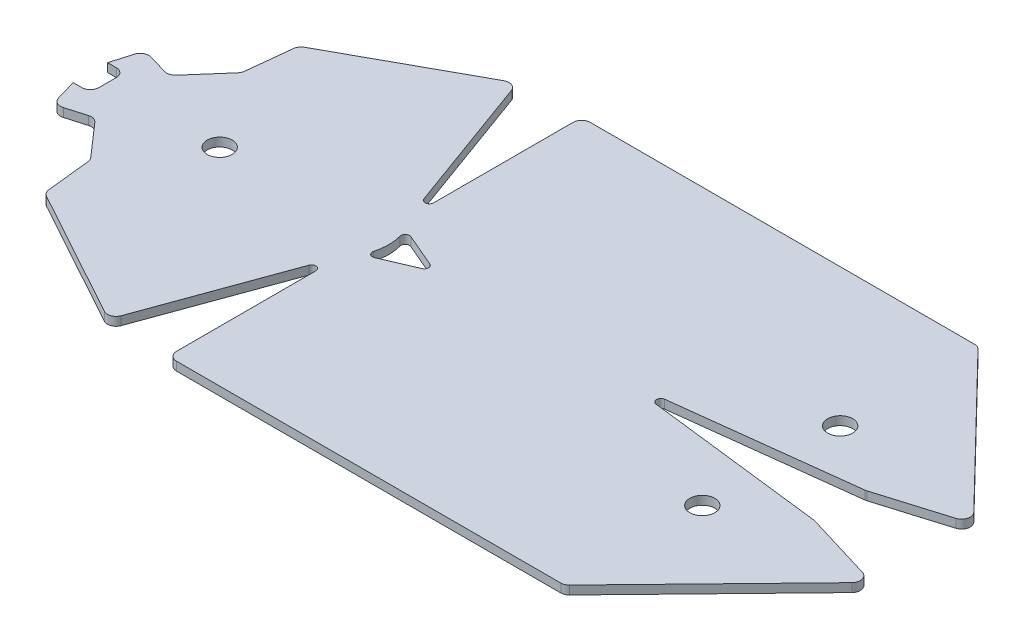
from build123d import *

# Parameters (mm, degrees)
BOSS_EXTRUDE2_DEPTH        = 1
FILLET1_R                  = 1
FILLET2_R                  = 0.5
M2_5_CLEARANCE_HOLE1_D     = 2.9
M2_5_CLEARANCE_HOLE1_DEPTH = 7.25
M2_5_CLEARANCE_HOLE1_TIP   = 0.871247898


with BuildPart() as part:
    # Sketch6 → Boss-Extrude2 (new body)
    with BuildSketch(Plane(origin=(0, 0, 0), x_dir=(1, 0, 0), z_dir=(0, 1, 0))):
        Polygon((-21.18242301, -23.733545037), (-14, -4), (-14, -24), (32, -24), (49.571034579, -5.897463907), (40, -3), (15, 0), (40, 3), (49.571034579, 5.897463907), (32, 24), (-14, 24), (-14, 4), (-21.18242301, 23.733545037), (-37.579939109, 14.722767652), (-38.229006165, 8.757978304), (-42.181953388, 4.244198486), (-46.02292771, 5.360852532), (-47, 2), (-45, 2), (-45, -2), (-47, -2), (-46.02292771, -5.360852532), (-42.181953388, -4.244198486), (-38.229006165, -8.757978304), (-37.579939109, -14.722767652), align=None)
        with BuildLine():
            Line((-7, 0), (-13.002008181, -2.57228922))
            ThreePointArc((-13.002008181, -2.57228922), (-12.400581568, 0), (-13.002008181, 2.57228922))
            Line((-13.002008181, 2.57228922), (-7, 0))
        make_face(mode=Mode.SUBTRACT)
    extrude(amount=BOSS_EXTRUDE2_DEPTH)

    # Fillet1
    fillet1_edges = [part.edges().sort_by_distance(p)[0] for p in [
        (-14, 0.5, -24),
        (32, 0.5, -24),
        (49.571034579, 0.5, -5.897463907),
        (40, 0.5, -3),
        (40, 0.5, 3),
        (49.571034579, 0.5, 5.897463907),
        (32, 0.5, 24),
        (-14, 0.5, 24),
        (-21.18242301, 0.5, 23.733545037),
        (-37.579939109, 0.5, 14.722767652),
        (-38.229006165, 0.5, 8.757978304),
        (-42.181953388, 0.5, 4.244198486),
        (-46.02292771, 0.5, 5.360852532),
        (-45, 0.5, 2),
        (-21.18242301, 0.5, -23.733545037),
        (-37.579939109, 0.5, -14.722767652),
        (-38.229006165, 0.5, -8.757978304),
        (-42.181953388, 0.5, -4.244198486),
        (-46.02292771, 0.5, -5.360852532),
        (-45, 0.5, -2),
    ]]
    fillet(fillet1_edges, radius=FILLET1_R)

    # Fillet2
    fillet2_edges = [part.edges().sort_by_distance(p)[0] for p in [
        (-7, 0.5, 0),
        (-13.002008181, 0.5, -2.57228922),
        (-14, 0.5, -4),
        (15, 0.5, 0),
        (-14, 0.5, 4),
        (-13.002008181, 0.5, 2.57228922),
    ]]
    fillet(fillet2_edges, radius=FILLET2_R)

    # M2.5 Clearance Hole1
    with Locations(Plane(origin=(0, 1, 0), x_dir=(1, 0, 0), z_dir=(0, 1, 0))):
        with Locations((-32, 0), (32, 8), (32, -8)):
            Hole(M2_5_CLEARANCE_HOLE1_D / 2, depth=M2_5_CLEARANCE_HOLE1_DEPTH)
            with Locations((0, 0, -(M2_5_CLEARANCE_HOLE1_DEPTH + M2_5_CLEARANCE_HOLE1_TIP / 2))):  # 118° drill point
                Cone(0, M2_5_CLEARANCE_HOLE1_D / 2, M2_5_CLEARANCE_HOLE1_TIP, mode=Mode.SUBTRACT)


solid = part.part
